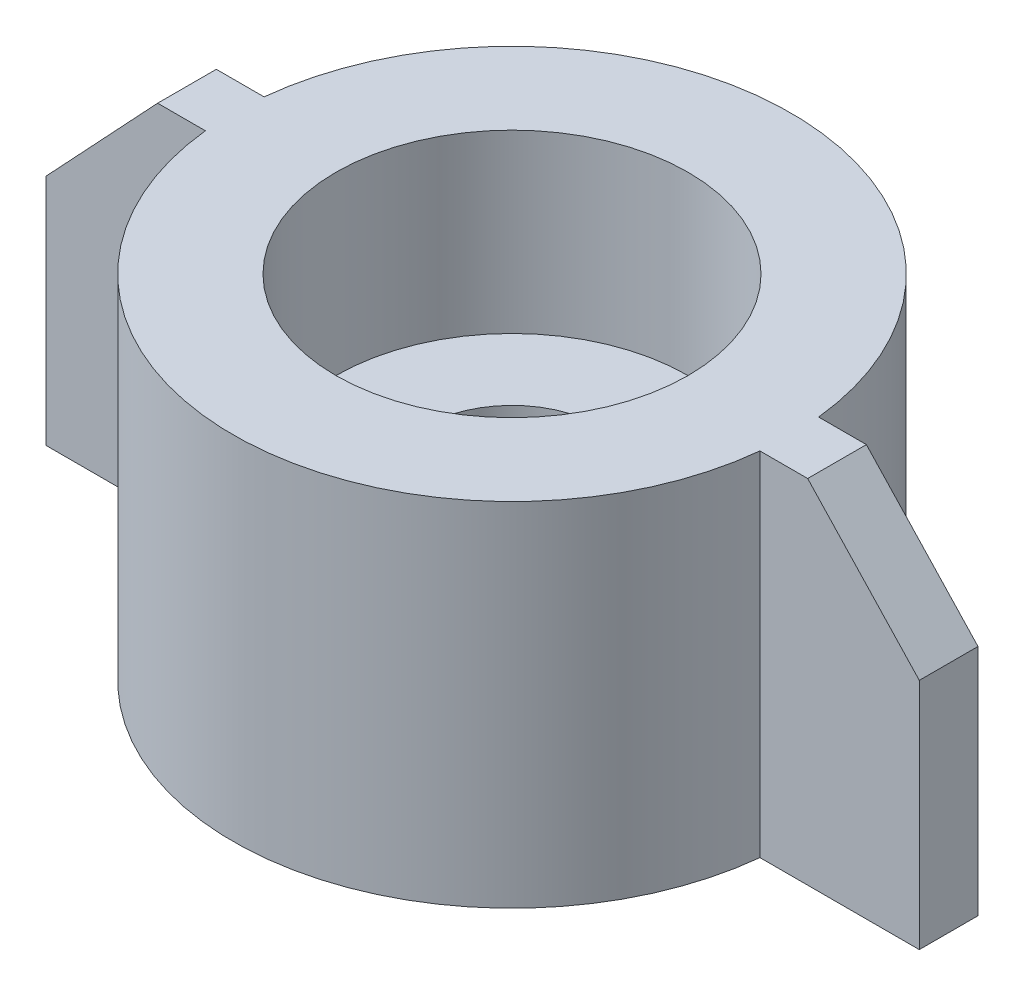
from build123d import *

# Parameters (mm, degrees)
SKETCH1_R           = 9.5
SKETCH1_R_2         = 6
BOSS_EXTRUDE1_DEPTH = 12
BOSS_EXTRUDE2_DEPTH = 1
CIRPATTERN1_COUNT   = 2
SKETCH3_R           = 6
SKETCH3_R_2         = 3
BOSS_EXTRUDE3_DEPTH = 2


with BuildPart() as part:
    # Sketch1 → Boss-Extrude1 (new body)
    with BuildSketch(Plane(origin=(0, 0, 0), x_dir=(1, 0, 0), z_dir=(0, 1, 0))):
        Circle(SKETCH1_R)
        Circle(SKETCH1_R_2, mode=Mode.SUBTRACT)
    extrude(amount=BOSS_EXTRUDE1_DEPTH)

    # Sketch2 → Boss-Extrude2 (add, symmetric)
    with BuildSketch(Plane.XY):
        Polygon((7.271324846, 12), (7.271324846, 0), (14.87673759, 0), (14.87673759, 7.945570702), (11.074031218, 12), align=None)
    boss_extrude2 = extrude(amount=BOSS_EXTRUDE2_DEPTH, both=True)

    # CirPattern1: Boss-Extrude2 ×2 about axis
    cirpattern1_axis = Axis((0, 12, 0), (0, -1, 0))
    for i in range(1, CIRPATTERN1_COUNT):
        add(boss_extrude2.rotate(cirpattern1_axis, i * 360 / CIRPATTERN1_COUNT))

    # Sketch3 → Boss-Extrude3 (add)
    with BuildSketch(Plane(origin=(0, 4, 0), x_dir=(1, 0, 0), z_dir=(0, 1, 0))):
        Circle(SKETCH3_R)
        Circle(SKETCH3_R_2, mode=Mode.SUBTRACT)
    extrude(amount=BOSS_EXTRUDE3_DEPTH)


solid = part.part
